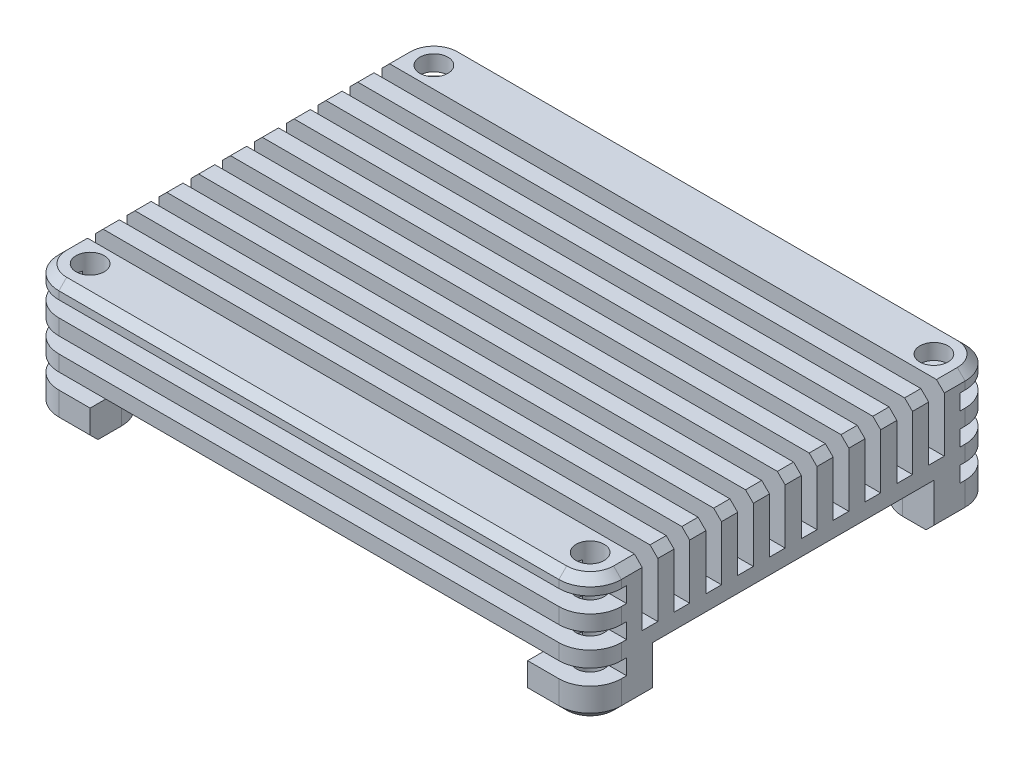
from build123d import *

# Parameters (mm, degrees)
ESQUISSE1_W                = 54
ESQUISSE1_H                = 39
BOSS_EXTRU_1_DEPTH         = 12
CONG_1_R                   = 3
CHANFREIN1_SIZE            = 0.75
ESQUISSE2_W                = 1.5
ESQUISSE2_H                = 6
ENL_V_MAT_EXTRU_1_DEPTH    = 55
ESQUISSE3_W                = 3.5
ESQUISSE3_H                = 1.5
ENL_V_MAT_EXTRU_2_DEPTH    = 55
R_P_TITION_LIN_AIRE1_COUNT = 10
R_P_TITION_LIN_AIRE1_PITCH = 3.055555556
ESQUISSE4_R                = 1.35
ENL_V_MAT_EXTRU_3_DEPTH    = 13
ENL_V_MAT_EXTRU_4_DEPTH    = 4.5


with BuildPart() as part:
    # Esquisse1 → Boss.-Extru.1 (new body)
    with BuildSketch(Plane(origin=(0, 0, 0), x_dir=(1, 0, 0), z_dir=(0, 1, 0))):
        Rectangle(ESQUISSE1_W, ESQUISSE1_H)
    extrude(amount=BOSS_EXTRU_1_DEPTH)

    # Congé1
    cong_1_edges = [part.edges().sort_by_distance(p)[0] for p in [
        (27, 6, 19.5),
        (-27, 6, 19.5),
        (-27, 6, -19.5),
        (27, 6, -19.5),
    ]]
    fillet(cong_1_edges, radius=CONG_1_R)

    # Chanfrein1
    chanfrein1_edges = [part.edges().sort_by_distance(p)[0] for p in [
        (0, 0, -19.5),
        (0, 12, -19.5),
        (27, 0, 0),
        (0, 0, 19.5),
        (-27, 0, 0),
        (-26.121320344, 0, 18.621320344),
        (-26.121320344, 0, -18.621320344),
        (26.121320344, 0, 18.621320344),
        (26.121320344, 0, -18.621320344),
        (27, 12, 0),
        (-27, 12, 0),
        (0, 12, 19.5),
        (-26.121320344, 12, 18.621320344),
        (-26.121320344, 12, -18.621320344),
        (26.121320344, 12, 18.621320344),
        (26.121320344, 12, -18.621320344),
    ]]
    chamfer(chanfrein1_edges, length=CHANFREIN1_SIZE)

    # Esquisse2 → Enlèv. mat.-Extru.1 (cut, through all)
    with BuildSketch(Plane.ZY.offset(27)):
        with Locations((-13.75, 9)):
            Rectangle(ESQUISSE2_W, ESQUISSE2_H)
    enl_v_mat_extru_1 = extrude(amount=-ENL_V_MAT_EXTRU_1_DEPTH, mode=Mode.SUBTRACT)

    # Esquisse3 → Enlèv. mat.-Extru.2 (cut, through all)
    with BuildSketch(Plane.ZY.offset(27)):
        with Locations((-17.75, 9.75)):
            Rectangle(ESQUISSE3_W, ESQUISSE3_H)
        with Locations((-17.75, 6.75)):
            Rectangle(ESQUISSE3_W, ESQUISSE3_H)
        with Locations((-17.75, 3.75)):
            Rectangle(ESQUISSE3_W, ESQUISSE3_H)
    enl_v_mat_extru_2 = extrude(amount=-ENL_V_MAT_EXTRU_2_DEPTH, mode=Mode.SUBTRACT)

    # Symétrie1: Enlèv. mat.-Extru.1, Enlèv. mat.-Extru.2 across plane
    add(enl_v_mat_extru_1.mirror(Plane.XY), mode=Mode.SUBTRACT)
    add(enl_v_mat_extru_2.mirror(Plane.XY), mode=Mode.SUBTRACT)

    # Répétition linéaire1: Enlèv. mat.-Extru.1 ×10
    with Locations(*[(0, 0, i * R_P_TITION_LIN_AIRE1_PITCH) for i in range(1, R_P_TITION_LIN_AIRE1_COUNT)]):
        add(enl_v_mat_extru_1, mode=Mode.SUBTRACT)

    # Esquisse4 → Enlèv. mat.-Extru.3 (cut, through all)
    with BuildSketch(Plane(origin=(0, 12, 0), x_dir=(1, 0, 0), z_dir=(0, 1, 0))):
        with Locations(Location((-24, 16.5, 0), (0, 0, 270))):  # turned: the seam where the file's is
            Circle(ESQUISSE4_R)
        with Locations(Location((24, 16.5, 0), (0, 0, 270))):  # turned: the seam where the file's is
            Circle(ESQUISSE4_R)
        with Locations(Location((24, -16.5, 0), (0, 0, 270))):  # turned: the seam where the file's is
            Circle(ESQUISSE4_R)
        with Locations(Location((-24, -16.5, 0), (0, 0, 270))):  # turned: the seam where the file's is
            Circle(ESQUISSE4_R)
    extrude(amount=-ENL_V_MAT_EXTRU_3_DEPTH, mode=Mode.SUBTRACT)

    # Esquisse5 → Enlèv. mat.-Extru.4 (cut)
    with BuildSketch(Plane.XZ):
        with BuildLine():
            Line((-24, 13.5), (-27, 13.5))
            Line((-27, 13.5), (-27, -13.5))
            Line((-27, -13.5), (-24, -13.5))
            ThreePointArc((-24, -13.5), (-21.878679656, -14.378679656), (-21, -16.5))
            Line((-21, -16.5), (-21, -19.5))
            Line((-21, -19.5), (21, -19.5))
            Line((21, -19.5), (21, -16.5))
            ThreePointArc((21, -16.5), (21.878679656, -14.378679656), (24, -13.5))
            Line((24, -13.5), (27, -13.5))
            Line((27, -13.5), (27, 13.5))
            Line((27, 13.5), (24, 13.5))
            ThreePointArc((24, 13.5), (21.878679656, 14.378679656), (21, 16.5))
            Line((21, 16.5), (21, 19.5))
            Line((21, 19.5), (-21, 19.5))
            Line((-21, 19.5), (-21, 16.5))
            ThreePointArc((-21, 16.5), (-21.878679656, 14.378679656), (-24, 13.5))
        make_face()
    extrude(amount=-ENL_V_MAT_EXTRU_4_DEPTH, mode=Mode.SUBTRACT)


solid = part.part
